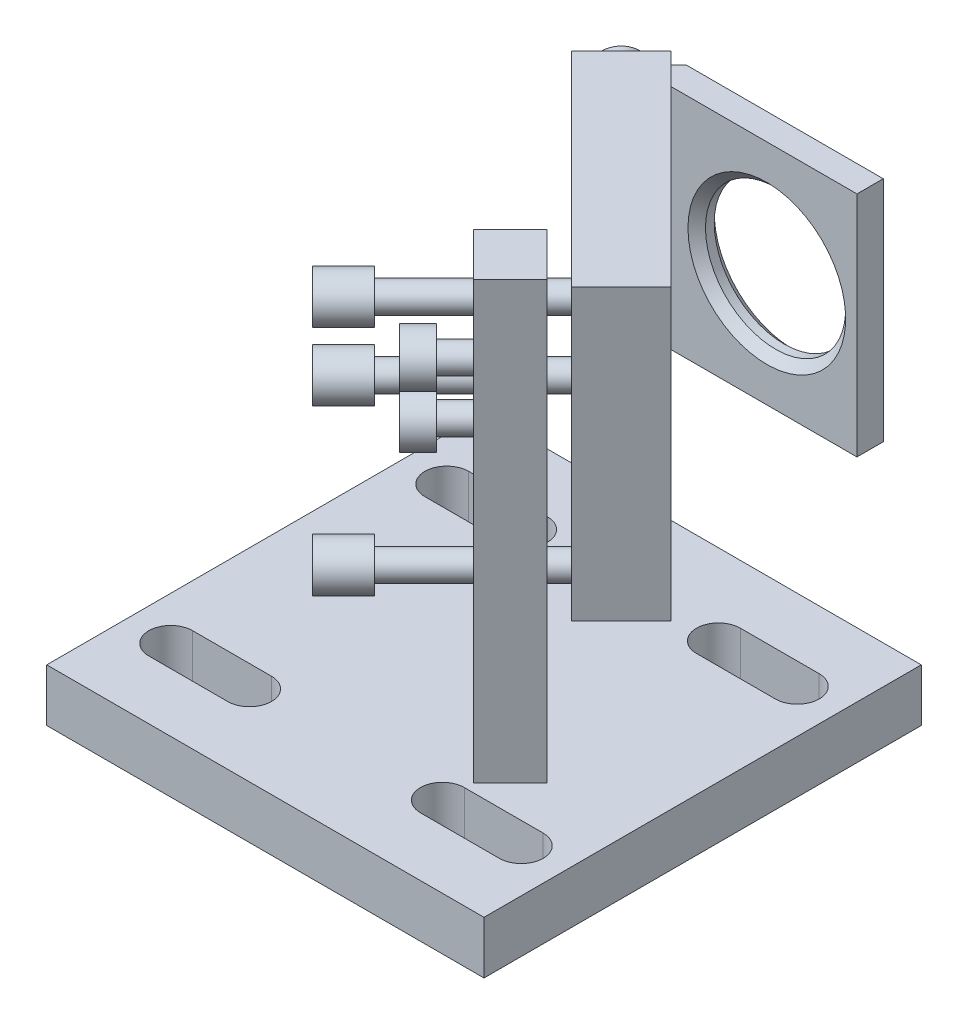
from build123d import *

# Parameters (mm, degrees)
SKETCH1_W                = 49.9
SKETCH1_H                = 49.9
BOSS_EXTRUDE1_DEPTH      = 6
BOSS_EXTRUDE2_DEPTH      = 5.9
SKETCH3_R                = 1.5
BOSS_EXTRUDE3_DEPTH      = 13
BOSS_EXTRUDE3_DEPTH_BACK = 14.9
SKETCH4_R                = 2.5
BOSS_EXTRUDE4_DEPTH      = 5
SKETCH5_R                = 1.5
BOSS_EXTRUDE5_DEPTH      = 3
SKETCH6_R                = 2.75
BOSS_EXTRUDE6_DEPTH      = 0.5
SKETCH7_R                = 2.75
BOSS_EXTRUDE7_DEPTH      = 2.5
SKETCH8_W                = 33
SKETCH8_H                = 33
SKETCH8_R                = 8.675
BOSS_EXTRUDE8_DEPTH      = 1
SKETCH9_W                = 33
SKETCH9_H                = 33
SKETCH9_R                = 10.15
BOSS_EXTRUDE9_DEPTH      = 7
SKETCH10_R               = 10
BOSS_EXTRUDE10_DEPTH     = 2
SKETCH11_R               = 10.15
SKETCH11_R_2             = 6
BOSS_EXTRUDE11_DEPTH     = 3
SKETCH12_R               = 2
CUT_EXTRUDE1_DEPTH       = 13
SKETCH13_R               = 4
CUT_EXTRUDE2_DEPTH       = 4
SKETCH14_R               = 3.5
BOSS_EXTRUDE12_DEPTH     = 1
SKETCH15_R               = 3.5
BOSS_EXTRUDE13_DEPTH     = 3
BOSS_EXTRUDE14_DEPTH     = 13
SKETCH17_R               = 8
CUT_EXTRUDE3_DEPTH       = 3
CHAMFER1_SIZE            = 1
SKETCH18_R               = 2.75
BOSS_EXTRUDE15_DEPTH     = 0.5
SKETCH19_R               = 2.75
BOSS_EXTRUDE16_DEPTH     = 2.5


with BuildPart() as part:
    # Sketch1 → Boss-Extrude1 (new body)
    with BuildSketch(Plane(origin=(0, -32.5, 0), x_dir=(1, 0, 0), z_dir=(0, 1, 0))):
        with Locations((-9.95, -9.95)):
            Rectangle(SKETCH1_W, SKETCH1_H)
        with BuildLine():
            Line((1.05, 8.3), (10.05, 8.3))
            ThreePointArc((10.05, 8.3), (12.55, 5.8), (10.05, 3.3))
            Line((10.05, 3.3), (1.05, 3.3))
            ThreePointArc((1.05, 3.3), (-1.45, 5.8), (1.05, 8.3))
        make_face(mode=Mode.SUBTRACT)
        with BuildLine():
            Line((-20.95, 8.3), (-29.95, 8.3))
            ThreePointArc((-29.95, 8.3), (-32.45, 5.8), (-29.95, 3.3))
            Line((-29.95, 3.3), (-20.95, 3.3))
            ThreePointArc((-20.95, 3.3), (-18.45, 5.8), (-20.95, 8.3))
        make_face(mode=Mode.SUBTRACT)
        with BuildLine():
            Line((-20.95, -28.2), (-29.95, -28.2))
            ThreePointArc((-29.95, -28.2), (-32.45, -25.7), (-29.95, -23.2))
            Line((-29.95, -23.2), (-20.95, -23.2))
            ThreePointArc((-20.95, -23.2), (-18.45, -25.7), (-20.95, -28.2))
        make_face(mode=Mode.SUBTRACT)
        with BuildLine():
            Line((1.05, -28.2), (10.05, -28.2))
            ThreePointArc((10.05, -28.2), (12.55, -25.7), (10.05, -23.2))
            Line((10.05, -23.2), (1.05, -23.2))
            ThreePointArc((1.05, -23.2), (-1.45, -25.7), (1.05, -28.2))
        make_face(mode=Mode.SUBTRACT)
    extrude(amount=-BOSS_EXTRUDE1_DEPTH)

    # Sketch2 → Boss-Extrude2 (add)
    with BuildSketch(Plane(origin=(-6.363961031, 0, 6.363961031), x_dir=(0, -1, 0), z_dir=(0.707106781, 0, -0.707106781))):
        with BuildLine():
            Line((-5.545268253, -9.5), (-17.25, -9.5))
            Line((-17.25, -9.5), (-17.25, -16.5))
            Line((-17.25, -16.5), (32.5, -16.5))
            Line((32.5, -16.5), (32.5, 16.5))
            Line((32.5, 16.5), (8.9, 16.5))
            Line((8.9, 16.5), (8.9, 6.464518544))
            ThreePointArc((8.9, 6.464518544), (8.156593612, -7.380378083), (-5.545268253, -9.5))
        make_face()
    extrude(amount=-BOSS_EXTRUDE2_DEPTH)

    # Sketch3 → Boss-Extrude3 (add, two sides)
    with BuildSketch(Plane(origin=(-10.53589104, 0, 10.53589104), x_dir=(0.707106781, 0, 0.707106781), z_dir=(-0.707106781, 0, 0.707106781))) as boss_extrude3_sk:
        with Locations((13.25, 13.25)):
            Circle(SKETCH3_R)
        with Locations((13.25, -13.25)):
            Circle(SKETCH3_R)
        with Locations((-13.25, -13.25)):
            Circle(SKETCH3_R)
    extrude(amount=BOSS_EXTRUDE3_DEPTH)
    extrude(boss_extrude3_sk.sketch, amount=-BOSS_EXTRUDE3_DEPTH_BACK)

    # Sketch4 → Boss-Extrude4 (add)
    with BuildSketch(Plane(origin=(-19.728279195, 0, 19.728279195), x_dir=(0.707106781, 0, 0.707106781), z_dir=(-0.707106781, 0, 0.707106781))):
        with Locations((13.25, 13.25)):
            Circle(SKETCH4_R)
        with Locations((13.25, -13.25)):
            Circle(SKETCH4_R)
        with Locations((-13.25, -13.25)):
            Circle(SKETCH4_R)
    extrude(amount=-BOSS_EXTRUDE4_DEPTH)

    # Sketch5 → Boss-Extrude5 (add)
    with BuildSketch(Plane(origin=(-10.53589104, 0, 10.53589104), x_dir=(0.707106781, 0, 0.707106781), z_dir=(-0.707106781, 0, 0.707106781))):
        with Locations((-7.25, -13.25)):
            Circle(SKETCH5_R)
        with Locations((13.25, 7.25)):
            Circle(SKETCH5_R)
    extrude(amount=BOSS_EXTRUDE5_DEPTH)

    # Sketch6 → Boss-Extrude6 (add)
    with BuildSketch(Plane(origin=(-12.657211383, 0, 12.657211383), x_dir=(0.707106781, 0, 0.707106781), z_dir=(-0.707106781, 0, 0.707106781))):
        with Locations((13.25, 7.25)):
            Circle(SKETCH6_R)
        with Locations((-7.25, -13.25)):
            Circle(SKETCH6_R)
    extrude(amount=BOSS_EXTRUDE6_DEPTH)

    # Sketch7 → Boss-Extrude7 (add)
    with BuildSketch(Plane(origin=(-13.010764774, 0, 13.010764774), x_dir=(0.707106781, 0, 0.707106781), z_dir=(-0.707106781, 0, 0.707106781))):
        with Locations((-7.25, -13.25)):
            Circle(SKETCH7_R)
        Polygon((-6.221372178, -12.237449687), (-7.612580383, -11.852907018), (-8.641208205, -12.865457332), (-8.278627822, -14.262550313), (-6.887419617, -14.647092982), (-5.858791795, -13.634542668), align=None, mode=Mode.SUBTRACT)
        with Locations((13.25, 7.25)):
            Circle(SKETCH7_R)
        Polygon((13.787086733, 5.910271978), (14.678781868, 7.045266744), (14.141695135, 8.384994766), (12.712913267, 8.589728022), (11.821218132, 7.454733256), (12.358304865, 6.115005234), align=None, mode=Mode.SUBTRACT)
    extrude(amount=BOSS_EXTRUDE7_DEPTH)

    # Sketch8 → Boss-Extrude8 (add)
    with BuildSketch(Plane(origin=(0, 0, 0), x_dir=(0, -1, 0), z_dir=(0.707106781, 0, -0.707106781))):
        Rectangle(SKETCH8_W, SKETCH8_H)
        Circle(SKETCH8_R, mode=Mode.SUBTRACT)
    extrude(amount=BOSS_EXTRUDE8_DEPTH)

    # Sketch9 → Boss-Extrude9 (add)
    with BuildSketch(Plane(origin=(0, 0, 0), x_dir=(0.707106781, 0, 0.707106781), z_dir=(-0.707106781, 0, 0.707106781))):
        Rectangle(SKETCH9_W, SKETCH9_H)
        Circle(SKETCH9_R, mode=Mode.SUBTRACT)
    extrude(amount=BOSS_EXTRUDE9_DEPTH)

    # Sketch10 → Boss-Extrude10 (add)
    with BuildSketch(Plane(origin=(0, 0, 0), x_dir=(0.707106781, 0, 0.707106781), z_dir=(-0.707106781, 0, 0.707106781))):
        Circle(SKETCH10_R)
    extrude(amount=BOSS_EXTRUDE10_DEPTH)

    # Sketch11 → Boss-Extrude11 (add)
    with BuildSketch(Plane(origin=(-1.414213562, 0, 1.414213562), x_dir=(0.707106781, 0, 0.707106781), z_dir=(-0.707106781, 0, 0.707106781))):
        Circle(SKETCH11_R)
        Circle(SKETCH11_R_2, mode=Mode.SUBTRACT)
    extrude(amount=BOSS_EXTRUDE11_DEPTH)

    # Sketch12 → Cut-Extrude1 (cut)
    with BuildSketch(Plane.XZ.offset(38.5)):
        with Locations((-15.344217152, 1.555634919)):
            Circle(SKETCH12_R)
        with Locations((-1.555634919, 15.344217152)):
            Circle(SKETCH12_R)
    extrude(amount=-CUT_EXTRUDE1_DEPTH, mode=Mode.SUBTRACT)

    # Sketch13 → Cut-Extrude2 (cut)
    with BuildSketch(Plane.XZ.offset(38.5)):
        with Locations((-15.344217152, 1.555634919)):
            Circle(SKETCH13_R)
        with Locations((-1.555634919, 15.344217152)):
            Circle(SKETCH13_R)
    extrude(amount=-CUT_EXTRUDE2_DEPTH, mode=Mode.SUBTRACT)

    # Sketch14 → Boss-Extrude12 (add)
    with BuildSketch(Plane.XZ.offset(34.5)):
        with Locations((-15.344217152, 1.555634919)):
            Circle(SKETCH14_R)
        with Locations((-1.555634919, 15.344217152)):
            Circle(SKETCH14_R)
    extrude(amount=BOSS_EXTRUDE12_DEPTH)

    # Sketch15 → Boss-Extrude13 (add)
    with BuildSketch(Plane.XZ.offset(35.5)):
        with Locations((-1.555634919, 15.344217152)):
            Circle(SKETCH15_R)
        Polygon((-2.665434879, 16.674008131), (-3.262167668, 15.047997683), (-2.152367708, 13.718206703), (-0.445834958, 14.014426173), (0.150897831, 15.640436621), (-0.958902129, 16.9702276), align=None, mode=Mode.SUBTRACT)
        with Locations((-15.344217152, 1.555634919)):
            Circle(SKETCH15_R)
        Polygon((-14.297928697, 2.935953893), (-16.016464221, 3.151906787), (-17.062752676, 1.771587813), (-16.390505606, 0.175315945), (-14.671970082, -0.04063695), (-13.625681628, 1.339682024), align=None, mode=Mode.SUBTRACT)
    extrude(amount=BOSS_EXTRUDE13_DEPTH)

    # Sketch16 → Boss-Extrude14 (add, symmetric)
    with BuildSketch(Plane(origin=(0, 0, 0), x_dir=(1, 0, 0), z_dir=(0, 1, 0))):
        Polygon((-10.960155108, 12.374368671), (-16.263455967, 7.071067812), (-18.384776311, 9.192388155), (-12.202795796, 15.374368671), (10.289844892, 15.374368671), (10.289844892, 12.374368671), align=None)
    extrude(amount=BOSS_EXTRUDE14_DEPTH, both=True)

    # Sketch17 → Cut-Extrude3 (cut)
    with BuildSketch(Plane(origin=(0, 0, -15.374368671), x_dir=(-1, 0, 0), z_dir=(0, 0, -1))):
        Circle(SKETCH17_R)
    extrude(amount=-CUT_EXTRUDE3_DEPTH, mode=Mode.SUBTRACT)

    # Chamfer1
    chamfer1_edges = [part.edges().sort_by_distance(p)[0] for p in [
        (8, 0, -12.374368671),
        (8, 0, -15.374368671),
    ]]
    chamfer(chamfer1_edges, length=CHAMFER1_SIZE)

    # Sketch18 → Boss-Extrude15 (add)
    with BuildSketch(Plane(origin=(-13.788582233, 0, -13.788582233), x_dir=(-0.707106781, 0, 0.707106781), z_dir=(-0.707106781, 0, -0.707106781))):
        with Locations((3, 10)):
            Circle(SKETCH18_R)
        with Locations((3, -10)):
            Circle(SKETCH18_R)
    extrude(amount=BOSS_EXTRUDE15_DEPTH)

    # Sketch19 → Boss-Extrude16 (add)
    with BuildSketch(Plane(origin=(-14.142135624, 0, -14.142135624), x_dir=(-0.707106781, 0, 0.707106781), z_dir=(-0.707106781, 0, -0.707106781))):
        with Locations((3, -10)):
            Circle(SKETCH19_R)
        Polygon((3.666920263, -11.280058865), (4.442023626, -10.062459543), (3.775103364, -8.782400678), (2.333079737, -8.719941135), (1.557976374, -9.937540457), (2.224896636, -11.217599322), align=None, mode=Mode.SUBTRACT)
        with Locations((3, 10)):
            Circle(SKETCH19_R)
        Polygon((1.848210491, 9.130106754), (3.177454895, 8.567574402), (4.329244404, 9.437467649), (4.151789509, 10.869893246), (2.822545105, 11.432425598), (1.670755596, 10.562532351), align=None, mode=Mode.SUBTRACT)
    extrude(amount=BOSS_EXTRUDE16_DEPTH)


solid = part.part
